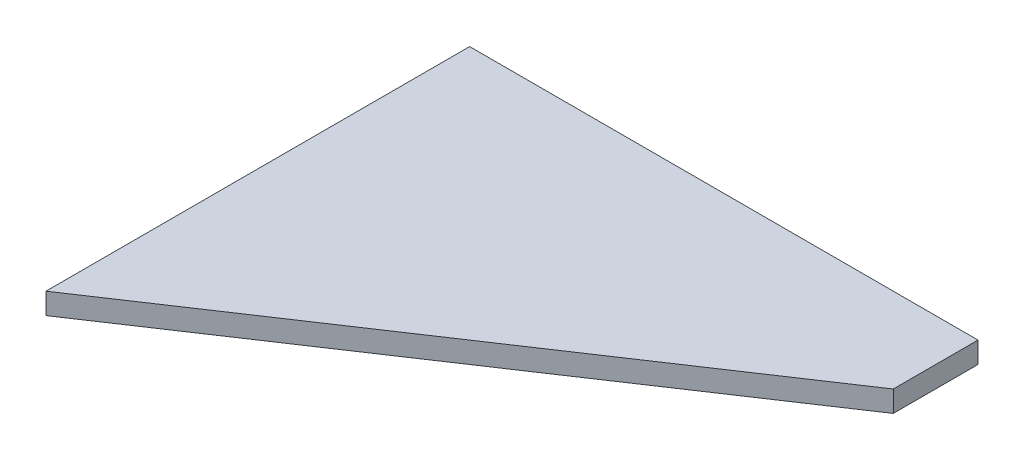
from build123d import *

# Parameters (mm, degrees)
BOSS_EXTRUDE2_DEPTH = 3.175


with BuildPart() as part:
    # Sketch2 → Boss-Extrude2 (new body)
    with BuildSketch(Plane(origin=(0, 0, 0), x_dir=(1, 0, 0), z_dir=(0, 1, 0))):
        Polygon((0, 0), (0, 63.5), (76.2, 63.5), (76.2, 50.8), align=None)
    extrude(amount=BOSS_EXTRUDE2_DEPTH)


solid = part.part
